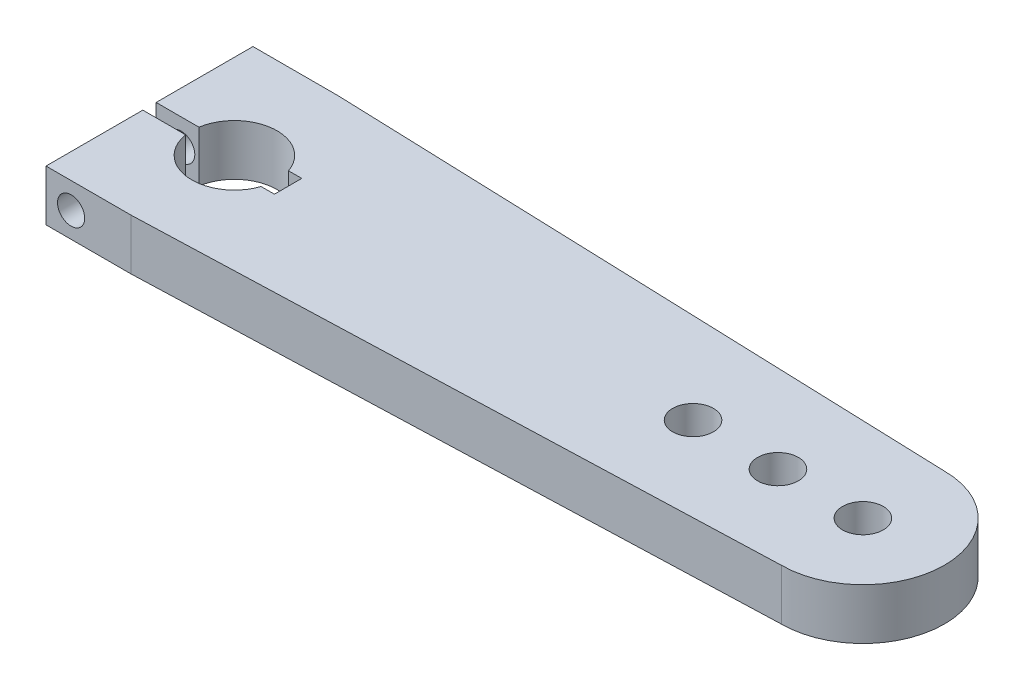
from build123d import *

# Parameters (mm, degrees)
SKETCH1_R               = 6
BOSS_EXTRUDE1_DEPTH     = 15
SKETCH2_R               = 4
CUT_EXTRUDE1_DEPTH      = 28.686687264
CUT_EXTRUDE1_DEPTH_BACK = 34.233997448
SKETCH3_W               = 25.445516604
SKETCH3_H               = 3.920684712
CUT_EXTRUDE2_DEPTH      = 16


with BuildPart() as part:
    # Sketch1 → Boss-Extrude1 (new body)
    with BuildSketch(Plane(origin=(0, 0, 0), x_dir=(1, 0, 0), z_dir=(0, 1, 0))):
        with BuildLine():
            Line((-92.842511891, 27.686687264), (92.157488109, 21.226344908))
            ThreePointArc((92.157488109, 21.226344908), (116.157488109, -2.773655092), (92.157488109, -26.773655092))
            Line((92.157488109, -26.773655092), (-92.842511891, -33.233997448))
            Line((-92.842511891, -33.233997448), (-117.842511891, -33.233997448))
            Line((-117.842511891, -33.233997448), (-117.842511891, 27.686687264))
            Line((-117.842511891, 27.686687264), (-92.842511891, 27.686687264))
        make_face()
        with Locations((67.157488109, -2.773655092)):
            Circle(SKETCH1_R, mode=Mode.SUBTRACT)
        with Locations((42.157488109, -2.773655092)):
            Circle(SKETCH1_R, mode=Mode.SUBTRACT)
        with Locations((92.157488109, -2.773655092)):
            Circle(SKETCH1_R, mode=Mode.SUBTRACT)
        with BuildLine():
            Line((-80.95546537, 1.251344908), (-77.042511891, 1.251344908))
            Line((-77.042511891, 1.251344908), (-77.042511891, -6.798655092))
            Line((-77.042511891, -6.798655092), (-80.95546537, -6.798655092))
            ThreePointArc((-80.95546537, -6.798655092), (-105.392511891, -2.773655092), (-80.95546537, 1.251344908))
        make_face(mode=Mode.SUBTRACT)
    extrude(amount=BOSS_EXTRUDE1_DEPTH)

    # Sketch2 → Cut-Extrude1 (cut, two sides)
    with BuildSketch(Plane(origin=(0.426421377, 0, 0), x_dir=(-1, 0, 0), z_dir=(0, 0, -1))) as cut_extrude1_sk:
        with Locations((110.888582208, 7.369250935)):
            Circle(SKETCH2_R)
    extrude(amount=CUT_EXTRUDE1_DEPTH, mode=Mode.SUBTRACT)
    extrude(cut_extrude1_sk.sketch, amount=-CUT_EXTRUDE1_DEPTH_BACK, mode=Mode.SUBTRACT)

    # Sketch3 → Cut-Extrude2 (cut, through all)
    with BuildSketch(Plane(origin=(0, 15, 0), x_dir=(1, 0, 0), z_dir=(0, 1, 0))):
        with Locations((-111.290746627, -2.773655092)):
            Rectangle(SKETCH3_W, SKETCH3_H)
    extrude(amount=-CUT_EXTRUDE2_DEPTH, mode=Mode.SUBTRACT)


solid = part.part
